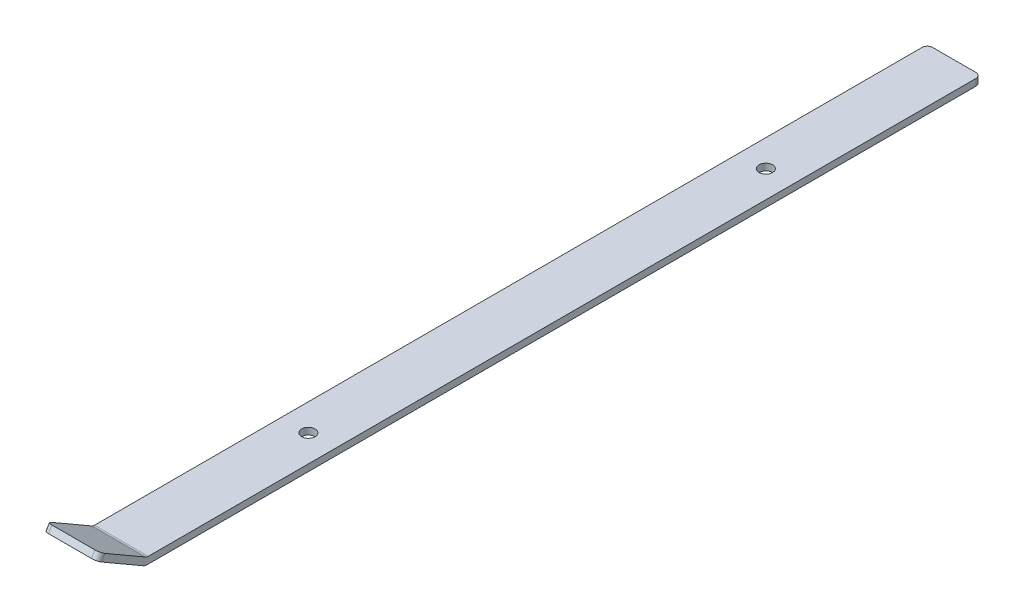
from build123d import *

# Parameters (mm, degrees)
BOSS_EXTRUDE1_DEPTH = 25.4
SKETCH2_R           = 3.175
CUT_EXTRUDE1_DEPTH  = 4.175
FILLET1_R           = 2.54


with BuildPart() as part:
    # Sketch1 → Boss-Extrude1 (new body)
    with BuildSketch(Plane(origin=(0, 0, 0), x_dir=(0, 0, -1), z_dir=(1, 0, 0))):
        with BuildLine():
            Line((0, 0), (-21.997045256, 12.7))
            Line((-21.997045256, 12.7), (-23.584545256, 9.950369343))
            Line((-23.584545256, 9.950369343), (-1.5875, -2.749630657))
            ThreePointArc((-1.5875, -2.749630657), (-0.821750468, -3.066814498), (0, -3.175))
            Line((0, -3.175), (393.7, -3.175))
            Line((393.7, -3.175), (393.7, 0))
            Line((393.7, 0), (0, 0))
        make_face()
    extrude(amount=BOSS_EXTRUDE1_DEPTH)

    # Sketch2 → Cut-Extrude1 (cut, through all)
    with BuildSketch(Plane(origin=(0, 0, 0), x_dir=(1, 0, 0), z_dir=(0, 1, 0))):
        with Locations((12.7, 88.9)):
            Circle(SKETCH2_R)
        with Locations((12.7, 304.8)):
            Circle(SKETCH2_R)
    extrude(amount=-CUT_EXTRUDE1_DEPTH, mode=Mode.SUBTRACT)

    # Fillet1
    fillet1_edges = [part.edges().sort_by_distance(p)[0] for p in [
        (25.4, 11.325184671, 22.790795256),
        (12.7, 0, 0),
        (25.4, -1.5875, -393.7),
        (0, -1.5875, -393.7),
        (0, 11.325184671, 22.790795256),
    ]]
    fillet(fillet1_edges, radius=FILLET1_R)


solid = part.part
